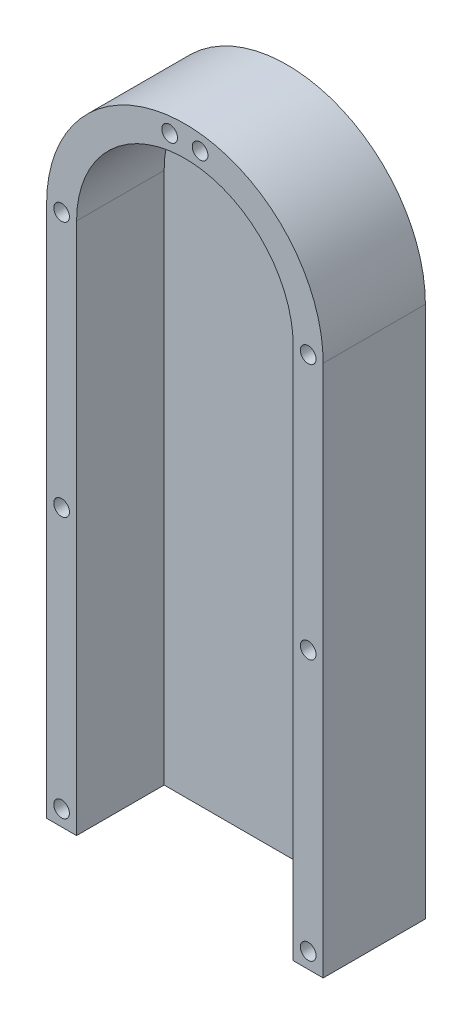
from build123d import *

# Parameters (mm, degrees)
SKETCH2_R           = 1.7
BOSS_EXTRUDE1_DEPTH = 3.175
SKETCH3_W           = 60
SKETCH3_H           = 160.555920096
CUT_EXTRUDE1_DEPTH  = 4.175
SKETCH4_R           = 1.7
BOSS_EXTRUDE2_DEPTH = 19


with BuildPart() as part:
    # Sketch2 → Boss-Extrude1 (new body)
    with BuildSketch(Plane.XY):
        with BuildLine():
            Line((54.582717937, -59.58290593), (54.582717937, 171.394622999))
            ThreePointArc((54.582717937, 171.394622999), (24.582717937, 201.394622999), (-5.417282063, 171.394622999))
            Line((-5.417282063, 171.394622999), (-5.417282063, -59.58290593))
            ThreePointArc((-5.417282063, -59.58290593), (24.582717937, -89.58290593), (54.582717937, -59.58290593))
        make_face()
        with Locations((27.882717937, 197.940291196)):
            Circle(SKETCH2_R, mode=Mode.SUBTRACT)
        with Locations((-2.167282063, -59.58290593)):
            Circle(SKETCH2_R, mode=Mode.SUBTRACT)
        with Locations((5.667611541, -78.498012327)):
            Circle(SKETCH2_R, mode=Mode.SUBTRACT)
        with Locations((21.182717937, -86.115951364)):
            Circle(SKETCH2_R, mode=Mode.SUBTRACT)
        with Locations((51.332717937, 171.394622999)):
            Circle(SKETCH2_R, mode=Mode.SUBTRACT)
        with Locations((-2.167282063, 59.305858535)):
            Circle(SKETCH2_R, mode=Mode.SUBTRACT)
        with Locations((27.982717937, -86.115951364)):
            Circle(SKETCH2_R, mode=Mode.SUBTRACT)
        with Locations((-2.167282063, 171.394622999)):
            Circle(SKETCH2_R, mode=Mode.SUBTRACT)
        with Locations((51.332717937, 115.905858535)):
            Circle(SKETCH2_R, mode=Mode.SUBTRACT)
        with Locations((-2.167282063, 115.905858535)):
            Circle(SKETCH2_R, mode=Mode.SUBTRACT)
        with Locations((43.497824334, -78.498012327)):
            Circle(SKETCH2_R, mode=Mode.SUBTRACT)
        with Locations((51.332717937, -59.58290593)):
            Circle(SKETCH2_R, mode=Mode.SUBTRACT)
        with Locations((51.332717937, -34.094141465)):
            Circle(SKETCH2_R, mode=Mode.SUBTRACT)
        with Locations((-2.167282063, -34.094141465)):
            Circle(SKETCH2_R, mode=Mode.SUBTRACT)
        with Locations((51.332717937, -4.094141465)):
            Circle(SKETCH2_R, mode=Mode.SUBTRACT)
        with Locations((-2.167282063, -4.094141465)):
            Circle(SKETCH2_R, mode=Mode.SUBTRACT)
        with Locations((51.332717937, 25.905858535)):
            Circle(SKETCH2_R, mode=Mode.SUBTRACT)
        with Locations((-2.167282063, 25.905858535)):
            Circle(SKETCH2_R, mode=Mode.SUBTRACT)
        with Locations((21.282717937, 197.940291196)):
            Circle(SKETCH2_R, mode=Mode.SUBTRACT)
        with Locations((51.332717937, 52.505858535)):
            Circle(SKETCH2_R, mode=Mode.SUBTRACT)
        with Locations((51.332717937, 59.305858535)):
            Circle(SKETCH2_R, mode=Mode.SUBTRACT)
        with Locations((-2.167282063, 52.505858535)):
            Circle(SKETCH2_R, mode=Mode.SUBTRACT)
    extrude(amount=BOSS_EXTRUDE1_DEPTH)

    # Sketch3 → Cut-Extrude1 (cut, through all)
    with BuildSketch(Plane.XY.offset(3.175)):
        with Locations((24.582717937, -24.372101513)):
            Rectangle(SKETCH3_W, SKETCH3_H)
    extrude(amount=-CUT_EXTRUDE1_DEPTH, mode=Mode.SUBTRACT)

    # Sketch4 → Boss-Extrude2 (add)
    with BuildSketch(Plane.XY.offset(3.175)):
        with BuildLine():
            Line((48.082717937, 171.394622999), (48.082717937, 55.905858535))
            Line((48.082717937, 55.905858535), (54.582717937, 55.905858535))
            Line((54.582717937, 55.905858535), (54.582717937, 171.394622999))
            ThreePointArc((54.582717937, 171.394622999), (24.582717937, 201.394622999), (-5.417282063, 171.394622999))
            Line((-5.417282063, 171.394622999), (-5.417282063, 55.905858535))
            Line((-5.417282063, 55.905858535), (1.082717937, 55.905858535))
            Line((1.082717937, 55.905858535), (1.082717937, 171.394622999))
            ThreePointArc((1.082717937, 171.394622999), (24.582717937, 194.894622999), (48.082717937, 171.394622999))
        make_face()
        with Locations((-2.167282063, 115.905858535)):
            Circle(SKETCH4_R, mode=Mode.SUBTRACT)
        with Locations((-2.167282063, 59.305858535)):
            Circle(SKETCH4_R, mode=Mode.SUBTRACT)
        with Locations((51.332717937, 59.305858535)):
            Circle(SKETCH4_R, mode=Mode.SUBTRACT)
        with Locations((51.332717937, 115.905858535)):
            Circle(SKETCH4_R, mode=Mode.SUBTRACT)
        with Locations((51.332717937, 171.394622999)):
            Circle(SKETCH4_R, mode=Mode.SUBTRACT)
        with Locations((27.882717937, 197.940291196)):
            Circle(SKETCH4_R, mode=Mode.SUBTRACT)
        with Locations((21.282717937, 197.940291196)):
            Circle(SKETCH4_R, mode=Mode.SUBTRACT)
        with Locations((-2.167282063, 171.394622999)):
            Circle(SKETCH4_R, mode=Mode.SUBTRACT)
    extrude(amount=BOSS_EXTRUDE2_DEPTH)


solid = part.part
